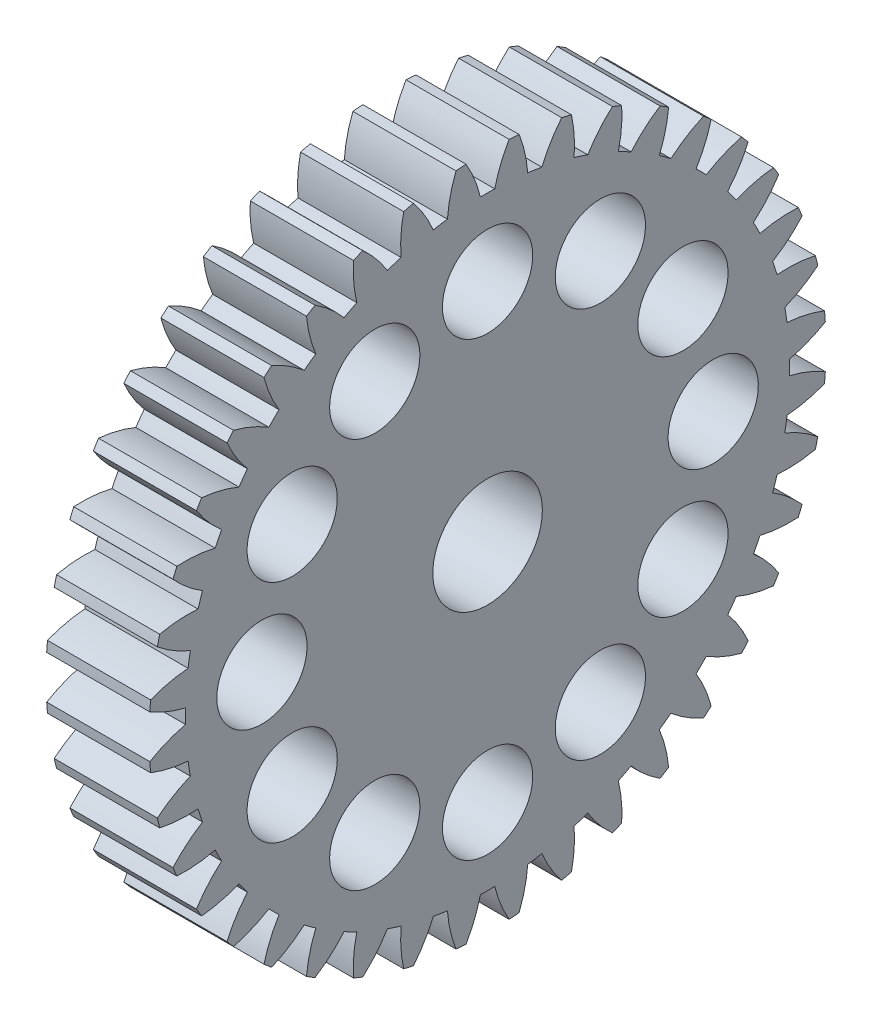
from build123d import *

# Parameters (mm, degrees)
BASPROSKE_W              = 8
BASPROSKE_H              = 26.25
TOOTHCUT_DEPTH           = 38.975320933
TEETHCUTS_COUNT          = 40
TEETHCUTS_ANGLE          = 351
BORSKE_R                 = 4
BORE_DEPTH               = 50.0000508
CUT_EXTRUDE_1_DEPTH      = 38.901747858
PATTERN_CIRCULAR_1_COUNT = 12
SKETCH_2_R               = 4.25
CUT_EXTRUDE_2_DEPTH      = 10


with BuildPart() as part:
    # BasProSke → Base-Revolve (revolve)
    with BuildSketch(Plane(origin=(0, 0, 0), x_dir=(1, 0, 0), z_dir=(0, 1, 0)), mode=Mode.PRIVATE) as base_revolve_sk:
        with Locations((4, 13.125)):
            Rectangle(BASPROSKE_W, BASPROSKE_H)
    revolve(base_revolve_sk.sketch.rotate(Axis((-10, 0, 0), (1, 0, 0)), 180), axis=Axis((-10, 0, 0), (1, 0, 0)))

    # TooCutSke → ToothCut (cut, through all)
    with BuildSketch(Plane(origin=(0, 0, 0), x_dir=(0, 0, -1), z_dir=(1, 0, 0))):
        with BuildLine():
            ThreePointArc((0.556797762, 23.429884944), (0, 23.4365), (-0.556797762, 23.429884944))
            ThreePointArc((-0.556797762, 23.429884944), (-1.015339965, 24.868305844), (-1.685200933, 26.221303228))
            ThreePointArc((-1.685200933, 26.221303228), (0, 26.2754), (1.685200933, 26.221303228))
            ThreePointArc((1.685200933, 26.221303228), (1.015339965, 24.868305844), (0.556797762, 23.429884944))
        make_face()
    toothcut = extrude(amount=TOOTHCUT_DEPTH, mode=Mode.SUBTRACT)

    # TeethCuts: ToothCut ×40 about axis
    teethcuts_axis = Axis((-10, 0, 0), (1, 0, 0))
    for i in range(1, TEETHCUTS_COUNT):
        add(toothcut.rotate(teethcuts_axis, i * TEETHCUTS_ANGLE / (TEETHCUTS_COUNT - 1)), mode=Mode.SUBTRACT)

    # BorSke → Bore (cut, symmetric)
    with BuildSketch(Plane(origin=(0, 0, 0), x_dir=(0, 0, -1), z_dir=(1, 0, 0))):
        with Locations(Location((0, 0, 0), (0, 0, 180))):
            Circle(BORSKE_R)
    extrude(amount=BORE_DEPTH, both=True, mode=Mode.SUBTRACT)

    # Эскиз1 → Вырез-Вытянуть1 (cut, symmetric)
    with BuildSketch(Plane(origin=(8, 0, 0), x_dir=(0, 0, -1), z_dir=(1, 0, 0))):
        with BuildLine():
            ThreePointArc((0, 21), (-3.5, 17.500000002), (-3e-09, 14))
            Line((0, 14), (0, 21))
        make_face()
        with BuildLine():
            Line((0, 21), (0, 14))
            ThreePointArc((-3e-09, 14), (2.474873733, 15.025126265), (3.5, 17.5))
            ThreePointArc((3.5, 17.5), (2.474873734, 19.974873734), (0, 21))
        make_face()
    cut_extrude_1 = extrude(amount=CUT_EXTRUDE_1_DEPTH, both=True, mode=Mode.SUBTRACT)

    # Круговой массив1: Вырез-Вытянуть1 ×12 about axis
    pattern_circular_1_axis = Axis((0, 0, 0), (1, 0, 0))
    for i in range(1, PATTERN_CIRCULAR_1_COUNT):
        add(cut_extrude_1.rotate(pattern_circular_1_axis, i * 360 / PATTERN_CIRCULAR_1_COUNT), mode=Mode.SUBTRACT)

    # Эскиз2 → Вырез-Вытянуть2 (cut)
    with BuildSketch(Plane(origin=(8, 0, 0), x_dir=(0, 0, -1), z_dir=(1, 0, 0))):
        Circle(SKETCH_2_R)
    extrude(amount=-CUT_EXTRUDE_2_DEPTH, mode=Mode.SUBTRACT)


solid = part.part
